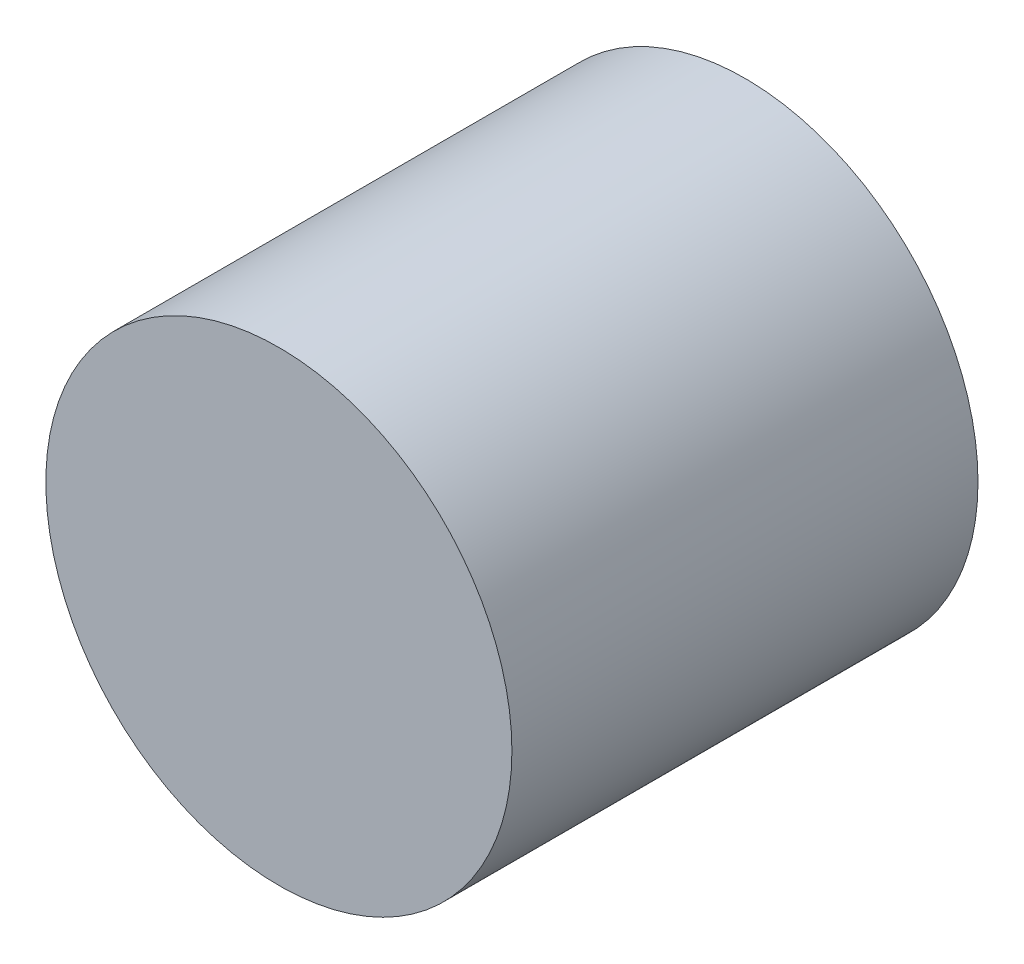
from build123d import *

# Parameters (mm, degrees)
CROQUIS1_R                          = 0.25
SALIENTE_EXTRUIR1_DEPTH             = 0.5
DI_METRO_DE_TALADRO_0_2_0_2_1_D     = 0.2
DI_METRO_DE_TALADRO_0_2_0_2_1_DEPTH = 0.25
DI_METRO_DE_TALADRO_0_2_0_2_1_TIP   = 0.060086062


with BuildPart() as part:
    # Croquis1 → Saliente-Extruir1 (new body)
    with BuildSketch(Plane.XY):
        Circle(CROQUIS1_R)
    extrude(amount=SALIENTE_EXTRUIR1_DEPTH)

    # Diámetro de taladro Ø0.2 (0.2)1
    with Locations(Plane(origin=(0, 0, 0), x_dir=(1, 0, 0), z_dir=(0, 0, -1))):
        with Locations((0, 0)):
            Hole(DI_METRO_DE_TALADRO_0_2_0_2_1_D / 2, depth=DI_METRO_DE_TALADRO_0_2_0_2_1_DEPTH)
            with Locations((0, 0, -(DI_METRO_DE_TALADRO_0_2_0_2_1_DEPTH + DI_METRO_DE_TALADRO_0_2_0_2_1_TIP / 2))):  # 118° drill point
                Cone(0, DI_METRO_DE_TALADRO_0_2_0_2_1_D / 2, DI_METRO_DE_TALADRO_0_2_0_2_1_TIP, mode=Mode.SUBTRACT)


solid = part.part
